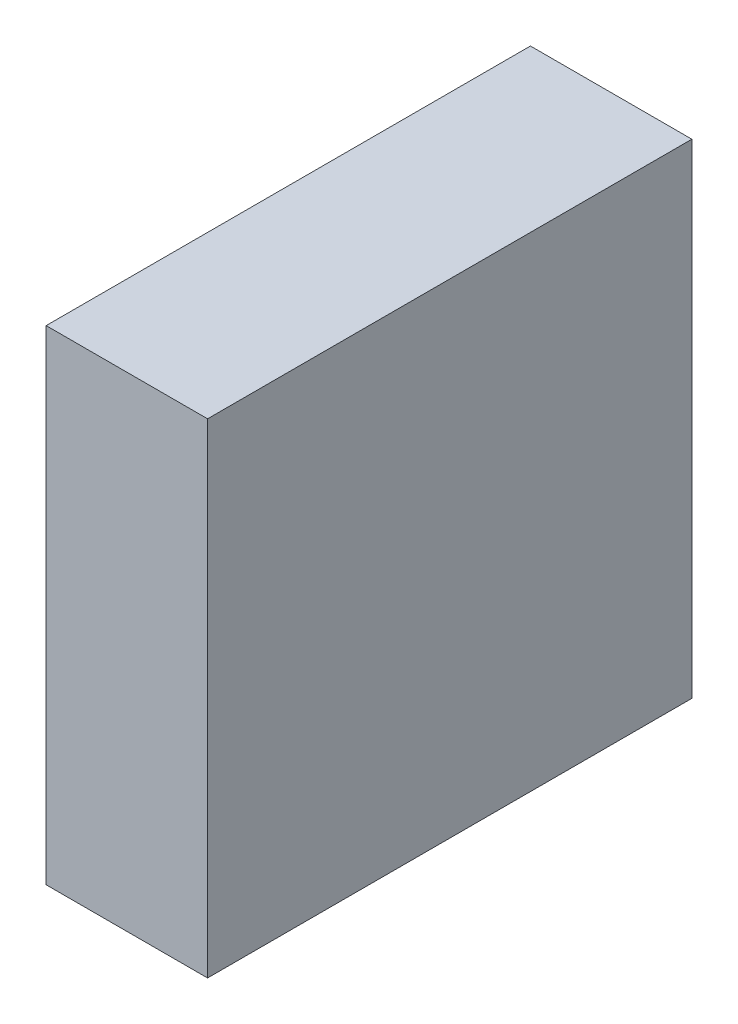
from build123d import *

# Parameters (mm, degrees)
SKETCH1_W           = 3
SKETCH1_H           = 9
BOSS_EXTRUDE1_DEPTH = 9


with BuildPart() as part:
    # Sketch1 → Boss-Extrude1 (new body)
    with BuildSketch(Plane(origin=(0, 0, 0), x_dir=(1, 0, 0), z_dir=(0, 1, 0))):
        with Locations((1.5, 4.5)):
            Rectangle(SKETCH1_W, SKETCH1_H)
    extrude(amount=BOSS_EXTRUDE1_DEPTH)


solid = part.part
